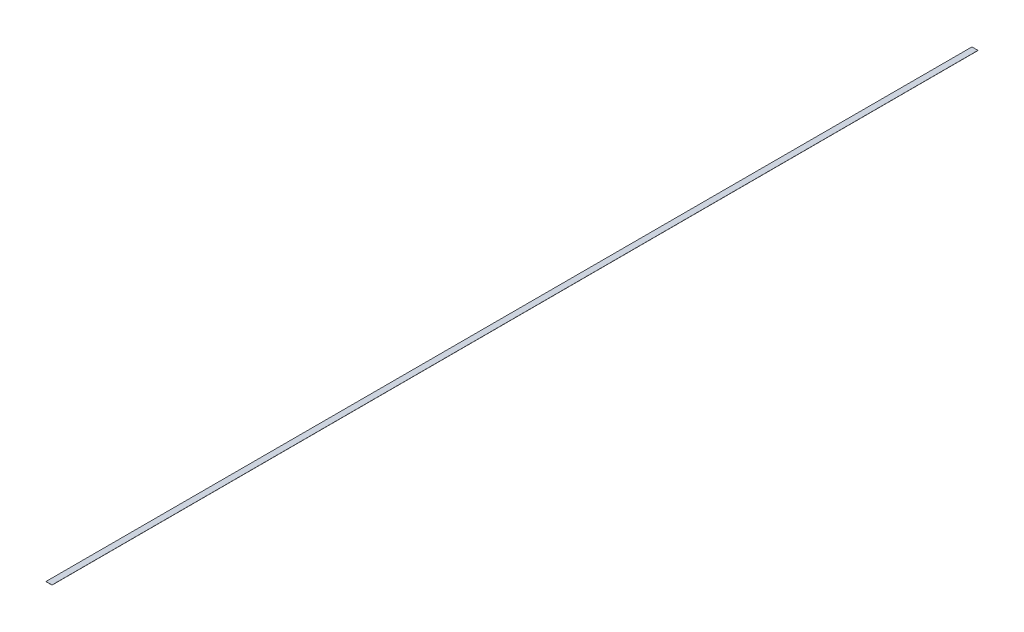
from build123d import *

# Parameters (mm, degrees)
SKETCH1_W           = 50.8
SKETCH1_H           = 7772.4
BOSS_EXTRUDE1_DEPTH = 1.27


with BuildPart() as part:
    # Sketch1 → Boss-Extrude1 (new body)
    with BuildSketch(Plane(origin=(0, 0, 0), x_dir=(1, 0, 0), z_dir=(0, 1, 0))):
        Rectangle(SKETCH1_W, SKETCH1_H)
    extrude(amount=BOSS_EXTRUDE1_DEPTH)


solid = part.part
